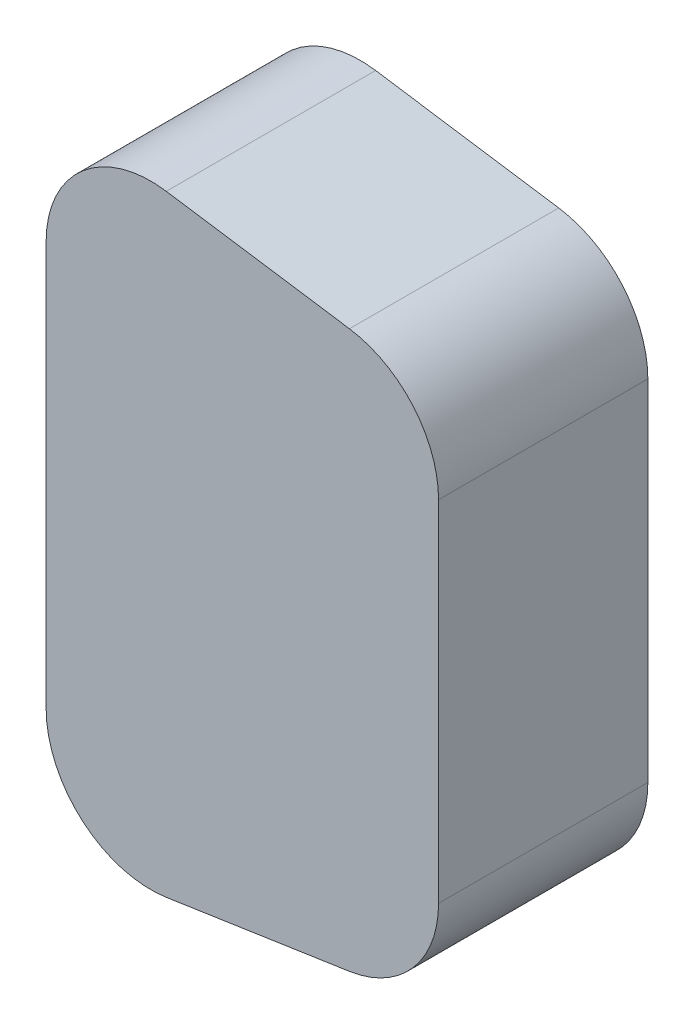
from build123d import *

# Parameters (mm, degrees)
BOSS_EXTRUDE1_DEPTH = 20
SKETCH5_W           = 9
SKETCH5_H           = 1.454272164
CUT_EXTRUDE4_DEPTH  = 10
SKETCH6_R           = 0.5
CUT_EXTRUDE5_DEPTH  = 5


with BuildPart() as part:
    # Sketch1 → Boss-Extrude1 (new body)
    with BuildSketch(Plane.XY):
        with BuildLine():
            Line((0, 19.325625792), (0, -19.325625792))
            ThreePointArc((0, -19.325625792), (3.474436626, -26.903027896), (11.483404529, -29.214989321))
            Line((11.483404529, -29.214989321), (28.983404529, -26.589989321))
            ThreePointArc((28.983404529, -26.589989321), (35.077402104, -23.226189166), (37.5, -16.700625792))
            Line((37.5, -16.700625792), (37.5, 16.700625792))
            ThreePointArc((37.5, 16.700625792), (35.077402104, 23.226189166), (28.983404529, 26.589989321))
            Line((28.983404529, 26.589989321), (11.483404529, 29.214989321))
            ThreePointArc((11.483404529, 29.214989321), (3.474436626, 26.903027896), (0, 19.325625792))
        make_face()
    extrude(amount=BOSS_EXTRUDE1_DEPTH)

    # Sketch5 → Cut-Extrude4 (cut)
    with BuildSketch(Plane.ZY):
        with Locations((10, 16.569972364)):
            Rectangle(SKETCH5_W, SKETCH5_H)
    extrude(amount=-CUT_EXTRUDE4_DEPTH, mode=Mode.SUBTRACT)

    # Sketch6 → Cut-Extrude5 (cut)
    with BuildSketch(Plane.XZ.offset(-17.297108446)):
        with Locations((2.644871575, 10)):
            Circle(SKETCH6_R)
    extrude(amount=-CUT_EXTRUDE5_DEPTH, mode=Mode.SUBTRACT)


solid = part.part
